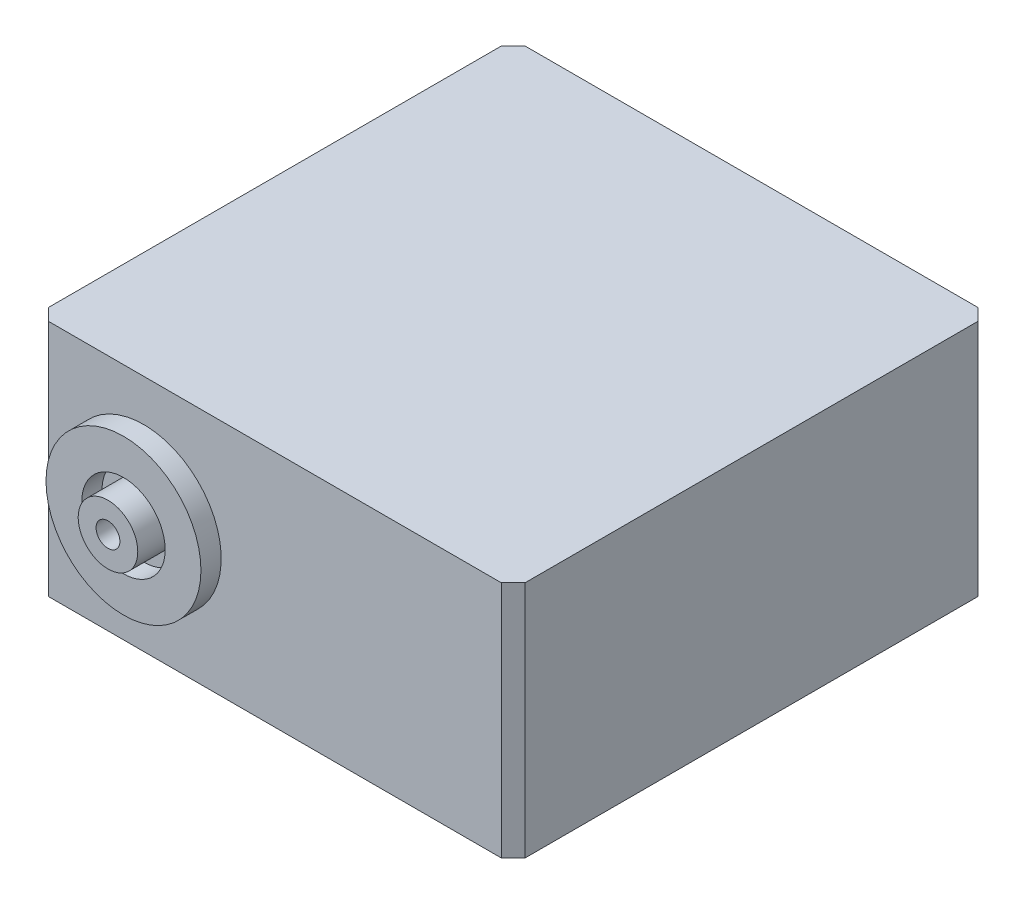
from build123d import *

# Parameters (mm, degrees)
EXTRUDE_1_DEPTH      = 20
SKETCH_4_R           = 6.5
SKETCH_4_R_2         = 3
EXTRUDE_2_DEPTH      = 1.7
SKETCH_5_R           = 3
EXTRUDE_3_DEPTH      = 2.7
SKETCH_6_R           = 3.2
EXTRUDE_4_DEPTH      = 3
SKETCH_7_R           = 1
CUT_EXTRUDE_41_DEPTH = 5.7
SKETCH_8_R           = 6.5
SKETCH_8_R_2         = 3.5
EXTRUDE_5_DEPTH      = 1.7
SKETCH_9_R           = 2.5
EXTRUDE_6_DEPTH      = 3
SKETCH_10_R          = 1
CUT_EXTRUDE_42_DEPTH = 5


with BuildPart() as part:
    # 草图1 → 凸台-拉伸1 (new body)
    with BuildSketch(Plane(origin=(0, 0, 0), x_dir=(1, 0, 0), z_dir=(0, 1, 0))):
        Polygon((-57.643399256, 26.149695183), (-19.643399256, 26.149695183), (-18.643399256, 25.149695183), (-18.643399256, -12.850304817), (-19.643399256, -13.850304817), (-57.643399256, -13.850304817), (-58.643399256, -12.850304817), (-58.643399256, 25.149695183), align=None)
    extrude(amount=EXTRUDE_1_DEPTH)

    # 草图4 → 凸台-拉伸2 (add)
    with BuildSketch(Plane(origin=(0, 0, -26.149695183), x_dir=(-1, 0, 0), z_dir=(0, 0, -1))):
        with Locations((49.643399256, 10)):
            Circle(SKETCH_4_R)
        with Locations((49.643399256, 10)):
            Circle(SKETCH_4_R_2, mode=Mode.SUBTRACT)
    extrude(amount=EXTRUDE_2_DEPTH)

    # 草图5 → 凸台-拉伸3 (add)
    with BuildSketch(Plane(origin=(0, 0, -26.149695183), x_dir=(-1, 0, 0), z_dir=(0, 0, -1))):
        with Locations((49.643399256, 10)):
            Circle(SKETCH_5_R)
    extrude(amount=EXTRUDE_3_DEPTH)

    # 草图6 → 凸台-拉伸4 (add)
    with BuildSketch(Plane(origin=(0, 0, -28.849695183), x_dir=(-1, 0, 0), z_dir=(0, 0, -1))):
        with Locations((49.643399256, 10)):
            Circle(SKETCH_6_R)
    extrude(amount=EXTRUDE_4_DEPTH)

    # 草图7 → 切除-拉伸41 (cut)
    with BuildSketch(Plane(origin=(0, 0, -31.849695183), x_dir=(-1, 0, 0), z_dir=(0, 0, -1))):
        with Locations((49.643399256, 10)):
            Circle(SKETCH_7_R)
    extrude(amount=-CUT_EXTRUDE_41_DEPTH, mode=Mode.SUBTRACT)

    # 草图8 → 凸台-拉伸5 (add)
    with BuildSketch(Plane.XY.offset(13.850304817)):
        with Locations((-49.643399256, 10)):
            Circle(SKETCH_8_R)
        with Locations((-49.643399256, 10)):
            Circle(SKETCH_8_R_2, mode=Mode.SUBTRACT)
    extrude(amount=EXTRUDE_5_DEPTH)

    # 草图9 → 凸台-拉伸6 (add)
    with BuildSketch(Plane.XY.offset(13.850304817)):
        with Locations((-49.643399256, 10)):
            Circle(SKETCH_9_R)
    extrude(amount=EXTRUDE_6_DEPTH)

    # 草图10 → 切除-拉伸42 (cut)
    with BuildSketch(Plane.XY.offset(16.850304817)):
        with Locations((-49.643399256, 10)):
            Circle(SKETCH_10_R)
    extrude(amount=-CUT_EXTRUDE_42_DEPTH, mode=Mode.SUBTRACT)


solid = part.part
